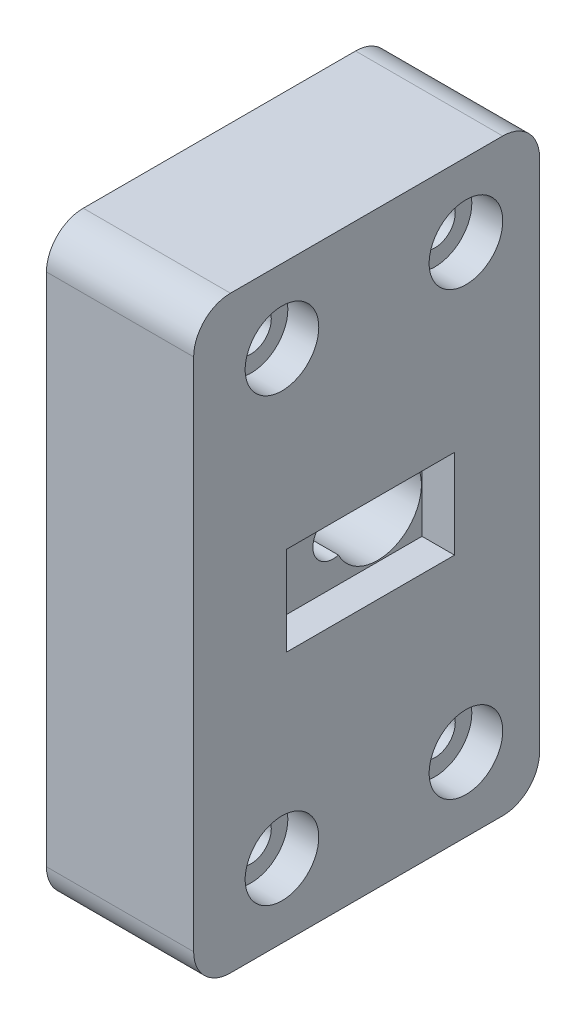
from build123d import *

# Parameters (mm, degrees)
ESQUISSE1_W                                        = 20
ESQUISSE1_H                                        = 80
BOSS_EXTRU_1_DEPTH                                 = 47
ESQUISSE2_R                                        = 13.05
ENL_V_MAT_EXTRU_1_DEPTH                            = 8
ENL_V_MAT_EXTRU_2_REACH                            = 14
CHAMBRAGE_POUR_VIS_T_TE_HEXAGONALE_M52_D           = 5.5
CHAMBRAGE_POUR_VIS_T_TE_HEXAGONALE_M52_CBORE_D     = 10
CHAMBRAGE_POUR_VIS_T_TE_HEXAGONALE_M52_CBORE_DEPTH = 4.2
CONG_1_R                                           = 5
ESQUISSE8_W                                        = 22.8
ESQUISSE8_H                                        = 12.1
ENL_V_MAT_EXTRU_4_DEPTH                            = 4.5
ENL_V_MAT_EXTRU_4_TAPER                            = -1
CHANFREIN1_SIZE                                    = 0.5


with BuildPart() as part:
    # Esquisse1 → Boss.-Extru.1 (new body)
    with BuildSketch(Plane.XY):
        with Locations((10, 40)):
            Rectangle(ESQUISSE1_W, ESQUISSE1_H)
    extrude(amount=BOSS_EXTRU_1_DEPTH)

    # Esquisse2 → Enlèv. mat.-Extru.1 (cut)
    with BuildSketch(Plane.ZY):
        with Locations((17.5, 40)):
            Circle(ESQUISSE2_R)
    extrude(amount=-ENL_V_MAT_EXTRU_1_DEPTH, mode=Mode.SUBTRACT)

    # Esquisse3 → Enlèv. mat.-Extru.2 (cut, up to next)
    with BuildSketch(Plane.ZY.offset(-8), mode=Mode.PRIVATE) as enl_v_mat_extru_2_sk1:
        with BuildLine():
            ThreePointArc((22.825826446, 42.652936611), (11.55, 40), (22.825826446, 37.347063389))
            ThreePointArc((22.825826446, 37.347063389), (26.3, 40), (22.825826446, 42.652936611))
        make_face()
    enl_v_mat_extru_2_tool1 = extrude(enl_v_mat_extru_2_sk1.sketch, amount=-ENL_V_MAT_EXTRU_2_REACH, mode=Mode.PRIVATE) & part.part
    add(enl_v_mat_extru_2_tool1.solids().sort_by_distance((8, 40, 18.266678))[0], mode=Mode.SUBTRACT)

    # Chambrage pour vis à tête hexagonale M52 (through all)
    with Locations(Plane(origin=(20, 0, 0), x_dir=(0, 0, -1), z_dir=(1, 0, 0))):
        with Locations((-10, 70), (-35, 70), (-35, 10), (-10, 10)):
            CounterBoreHole(CHAMBRAGE_POUR_VIS_T_TE_HEXAGONALE_M52_D / 2, CHAMBRAGE_POUR_VIS_T_TE_HEXAGONALE_M52_CBORE_D / 2, CHAMBRAGE_POUR_VIS_T_TE_HEXAGONALE_M52_CBORE_DEPTH)

    # Congé1
    cong_1_edges = [part.edges().sort_by_distance(p)[0] for p in [
        (10, 80, 47),
        (10, 80, 0),
        (10, 0, 0),
        (10, 0, 47),
    ]]
    fillet(cong_1_edges, radius=CONG_1_R)

    # Esquisse8 → Enlèv. mat.-Extru.4 (cut)
    with BuildSketch(Plane(origin=(20, 0, 0), x_dir=(0, 0, -1), z_dir=(1, 0, 0))):
        with Locations((-22.95, 40)):
            Rectangle(ESQUISSE8_W, ESQUISSE8_H)
    extrude(amount=-ENL_V_MAT_EXTRU_4_DEPTH, taper=ENL_V_MAT_EXTRU_4_TAPER, mode=Mode.SUBTRACT)

    # Chanfrein1
    chanfrein1_edges = [part.edges().sort_by_distance(p)[0] for p in [
        (0, 40, 4.45),
    ]]
    chamfer(chanfrein1_edges, length=CHANFREIN1_SIZE)


solid = part.part
